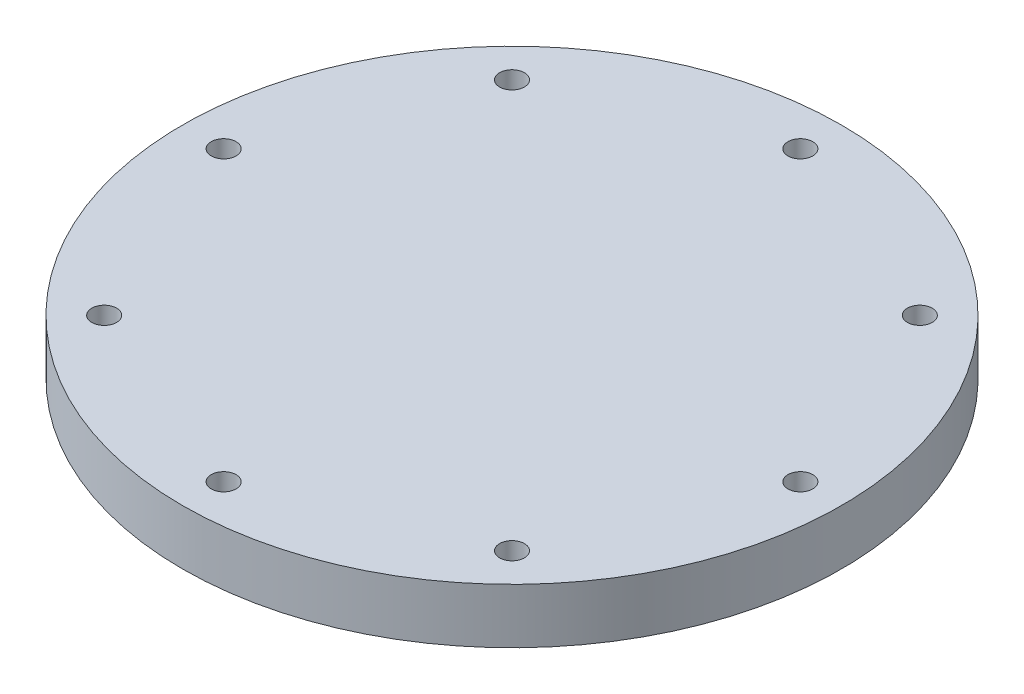
from build123d import *

# Parameters (mm, degrees)
SKETCH1_R                                      = 38.1
BOSS_EXTRUDE1_DEPTH                            = 6.35
CBORE_FOR_4_BUTTON_HEAD_CAP_SCREW1_D           = 2.8702
CBORE_FOR_4_BUTTON_HEAD_CAP_SCREW1_CBORE_D     = 4.826
CBORE_FOR_4_BUTTON_HEAD_CAP_SCREW1_CBORE_DEPTH = 1.905
CIRPATTERN1_COUNT                              = 8


with BuildPart() as part:
    # Sketch1 → Boss-Extrude1 (new body)
    with BuildSketch(Plane(origin=(0, 0, 0), x_dir=(1, 0, 0), z_dir=(0, 1, 0))):
        Circle(SKETCH1_R)
    extrude(amount=BOSS_EXTRUDE1_DEPTH)

    # CBORE for #4 Button Head Cap Screw1 (through all)
    with Locations(Plane(origin=(0, 0, 0), x_dir=(-1, 0, 0), z_dir=(0, -1, 0))):
        with Locations((0, -33.3375)):
            cbore_for_4_button_head_cap_screw1 = CounterBoreHole(CBORE_FOR_4_BUTTON_HEAD_CAP_SCREW1_D / 2, CBORE_FOR_4_BUTTON_HEAD_CAP_SCREW1_CBORE_D / 2, CBORE_FOR_4_BUTTON_HEAD_CAP_SCREW1_CBORE_DEPTH)

    # CirPattern1: CBORE for #4 Button Head Cap Screw1 ×8 about axis
    cirpattern1_axis = Axis((0, 0, 0), (0, 1, 0))
    for i in range(1, CIRPATTERN1_COUNT):
        add(cbore_for_4_button_head_cap_screw1.rotate(cirpattern1_axis, i * 360 / CIRPATTERN1_COUNT), mode=Mode.SUBTRACT)


solid = part.part
